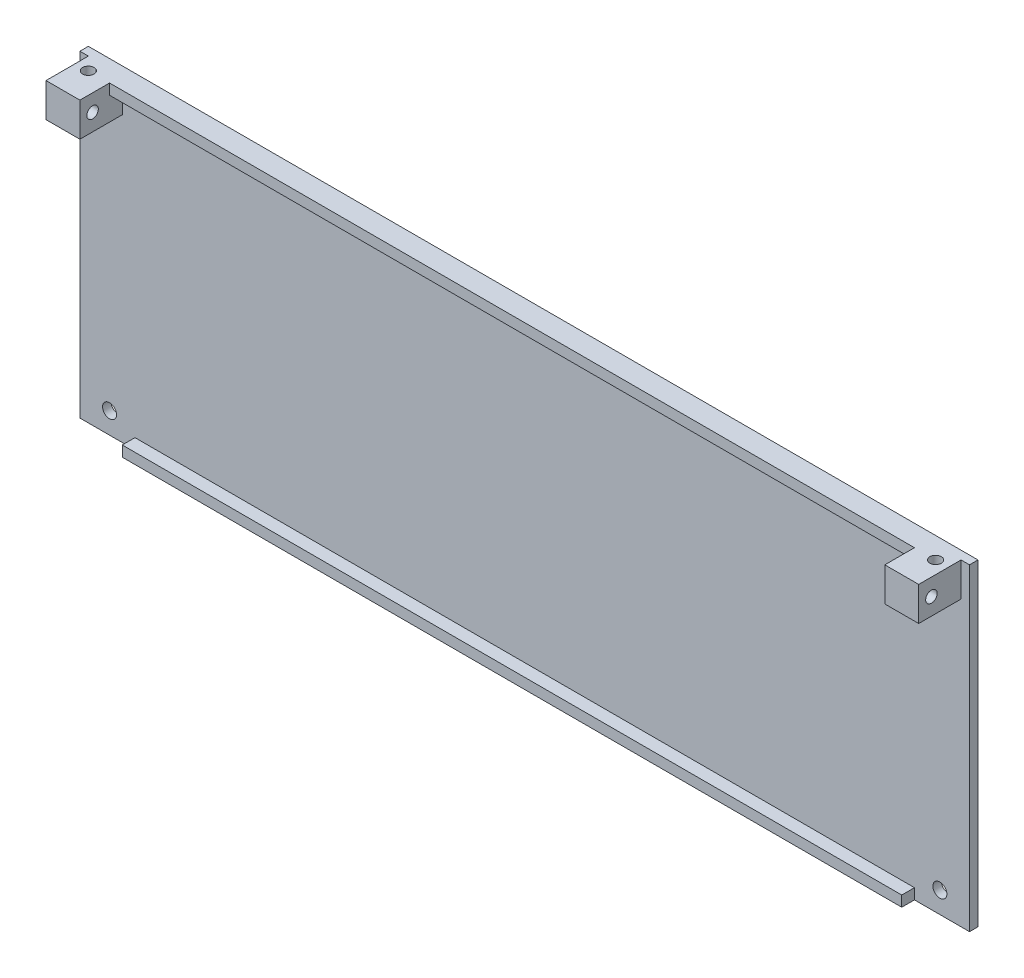
from build123d import *

# Parameters (mm, degrees)
SKETCH1_W           = 210
SKETCH1_H           = 75
SKETCH1_R           = 1.65
BOSS_EXTRUDE1_DEPTH = 2
SKETCH2_W           = 8
SKETCH2_H           = 8
BOSS_EXTRUDE2_DEPTH = 10
SKETCH3_R           = 1.35
CUT_EXTRUDE1_DEPTH  = 10
SKETCH4_W           = 190
SKETCH4_H           = 2.5
BOSS_EXTRUDE3_DEPTH = 3
SKETCH5_W           = 184
SKETCH5_H           = 2.5
BOSS_EXTRUDE4_DEPTH = 3
SKETCH6_R           = 1.35
CUT_EXTRUDE2_DEPTH  = 209


with BuildPart() as part:
    # Sketch1 → Boss-Extrude1 (new body)
    with BuildSketch(Plane.XY):
        Rectangle(SKETCH1_W, SKETCH1_H)
        with Locations((-98, -32.5)):
            Circle(SKETCH1_R, mode=Mode.SUBTRACT)
        with Locations((98, -32.5)):
            Circle(SKETCH1_R, mode=Mode.SUBTRACT)
    extrude(amount=BOSS_EXTRUDE1_DEPTH)

    # Sketch2 → Boss-Extrude2 (add)
    with BuildSketch(Plane.XY.offset(2)):
        with Locations((-99, 33.5)):
            Rectangle(SKETCH2_W, SKETCH2_H)
        with Locations((99, 33.5)):
            Rectangle(SKETCH2_W, SKETCH2_H)
    extrude(amount=BOSS_EXTRUDE2_DEPTH)

    # Sketch3 → Cut-Extrude1 (cut)
    with BuildSketch(Plane(origin=(0, 37.5, 0), x_dir=(1, 0, 0), z_dir=(0, 1, 0))):
        with Locations((-100, -5)):
            Circle(SKETCH3_R)
        with Locations((100, -5)):
            Circle(SKETCH3_R)
    extrude(amount=-CUT_EXTRUDE1_DEPTH, mode=Mode.SUBTRACT)

    # Sketch4 → Boss-Extrude3 (add)
    with BuildSketch(Plane.XY.offset(2)):
        with Locations((0, 36.25)):
            Rectangle(SKETCH4_W, SKETCH4_H)
    extrude(amount=BOSS_EXTRUDE3_DEPTH)

    # Sketch5 → Boss-Extrude4 (add)
    with BuildSketch(Plane.XY.offset(2)):
        with Locations((0, -36.25)):
            Rectangle(SKETCH5_W, SKETCH5_H)
    extrude(amount=BOSS_EXTRUDE4_DEPTH)

    # Sketch6 → Cut-Extrude2 (cut, through all)
    with BuildSketch(Plane(origin=(103, 0, 0), x_dir=(0, 0, -1), z_dir=(1, 0, 0))):
        with Locations((-9, 33.5)):
            Circle(SKETCH6_R)
    extrude(amount=-CUT_EXTRUDE2_DEPTH, mode=Mode.SUBTRACT)


solid = part.part
